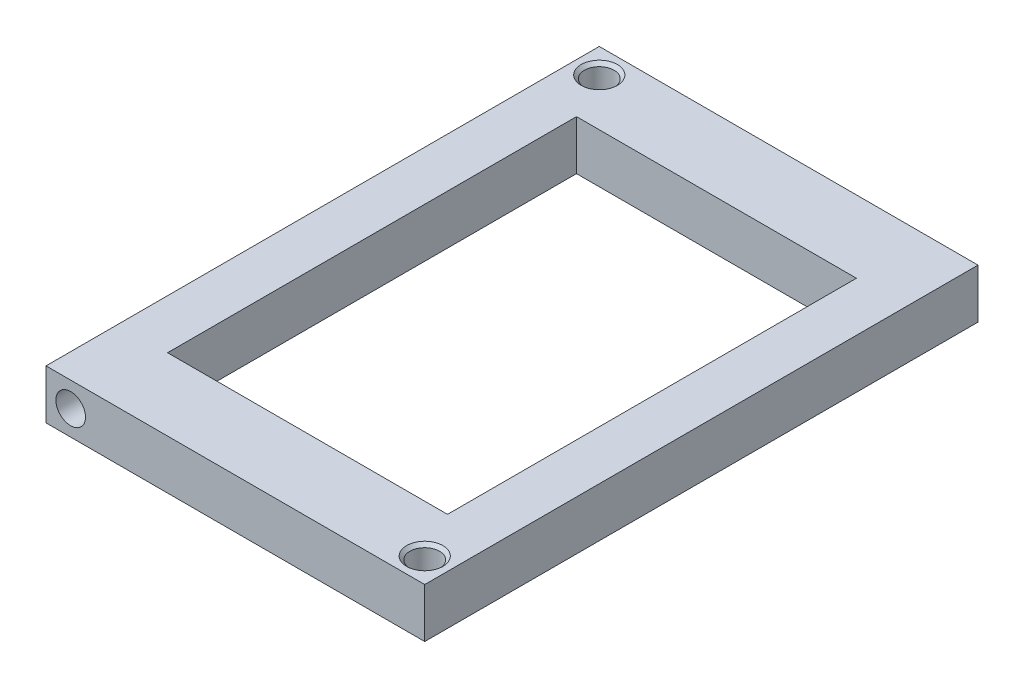
from build123d import *

# Parameters (mm, degrees)
BOSS_EXTRU_1_DEPTH      = 84
ESQUISSE3_R             = 2.25
ENL_V_MAT_EXTRU_1_DEPTH = 25
ENL_V_MAT_EXTRU_2_REACH = 9.5
ESQUISSE4_R             = 2.25
ESQUISSE4_W             = 42.5
ESQUISSE4_H             = 62.086956522
ESQUISSE5_R             = 2.25
ENL_V_MAT_EXTRU_3_DEPTH = 25
CHANFREIN1_SIZE         = 0.5


with BuildPart() as part:
    # Esquisse1 → Boss.-Extru.1 (new body)
    with BuildSketch(Plane.XY):
        Polygon((-15.842295968, 13.667406166), (-23.342295968, 13.667406166), (-23.342295968, 21.167406166), (34.157704032, 21.167406166), (34.157704032, 13.667406166), (26.657704032, 13.667406166), align=None)
    extrude(amount=BOSS_EXTRU_1_DEPTH)

    # Esquisse3 → Enlèv. mat.-Extru.1 (cut)
    with BuildSketch(Plane.XY.offset(84)):
        with Locations((-19.592295968, 17.417406166)):
            Circle(ESQUISSE3_R)
    extrude(amount=-ENL_V_MAT_EXTRU_1_DEPTH, mode=Mode.SUBTRACT)

    # Esquisse4 → Enlèv. mat.-Extru.2 (cut, up to next)
    with BuildSketch(Plane(origin=(0, 21.167406166, 0), x_dir=(1, 0, 0), z_dir=(0, 1, 0)), mode=Mode.PRIVATE) as enl_v_mat_extru_2_sk1:
        with Locations((30.407704032, -80.25)):
            Circle(ESQUISSE4_R)
    enl_v_mat_extru_2_tool1 = extrude(enl_v_mat_extru_2_sk1.sketch, amount=-ENL_V_MAT_EXTRU_2_REACH, mode=Mode.PRIVATE) & part.part
    add(enl_v_mat_extru_2_tool1.solids().sort_by_distance((30.407704, 21.167406, 80.25))[0], mode=Mode.SUBTRACT)
    # Esquisse4 → Enlèv. mat.-Extru.2 (cut, up to next)
    with BuildSketch(Plane(origin=(0, 21.167406166, 0), x_dir=(1, 0, 0), z_dir=(0, 1, 0)), mode=Mode.PRIVATE) as enl_v_mat_extru_2_sk2:
        with Locations((-19.592295968, -3.75)):
            Circle(ESQUISSE4_R)
    enl_v_mat_extru_2_tool2 = extrude(enl_v_mat_extru_2_sk2.sketch, amount=-ENL_V_MAT_EXTRU_2_REACH, mode=Mode.PRIVATE) & part.part
    add(enl_v_mat_extru_2_tool2.solids().sort_by_distance((-19.592296, 21.167406, 3.75))[0], mode=Mode.SUBTRACT)
    # Esquisse4 → Enlèv. mat.-Extru.2 (cut, up to next)
    with BuildSketch(Plane(origin=(0, 21.167406166, 0), x_dir=(1, 0, 0), z_dir=(0, 1, 0)), mode=Mode.PRIVATE) as enl_v_mat_extru_2_sk3:
        with Locations((5.407704032, -42)):
            Rectangle(ESQUISSE4_W, ESQUISSE4_H)
    enl_v_mat_extru_2_tool3 = extrude(enl_v_mat_extru_2_sk3.sketch, amount=-ENL_V_MAT_EXTRU_2_REACH, mode=Mode.PRIVATE) & part.part
    add(enl_v_mat_extru_2_tool3.solids().sort_by_distance((5.407704, 21.167406, 42))[0], mode=Mode.SUBTRACT)

    # Esquisse5 → Enlèv. mat.-Extru.3 (cut)
    with BuildSketch(Plane(origin=(0, 0, 0), x_dir=(-1, 0, 0), z_dir=(0, 0, -1))):
        with Locations((-30.407704032, 17.417406166)):
            Circle(ESQUISSE5_R)
    extrude(amount=-ENL_V_MAT_EXTRU_3_DEPTH, mode=Mode.SUBTRACT)

    # Chanfrein1
    chanfrein1_edges = [part.edges().sort_by_distance(p)[0] for p in [
        (28.157704032, 21.167406166, 80.25),
        (-21.842295968, 21.167406166, 3.75),
    ]]
    chamfer(chanfrein1_edges, length=CHANFREIN1_SIZE)


solid = part.part
